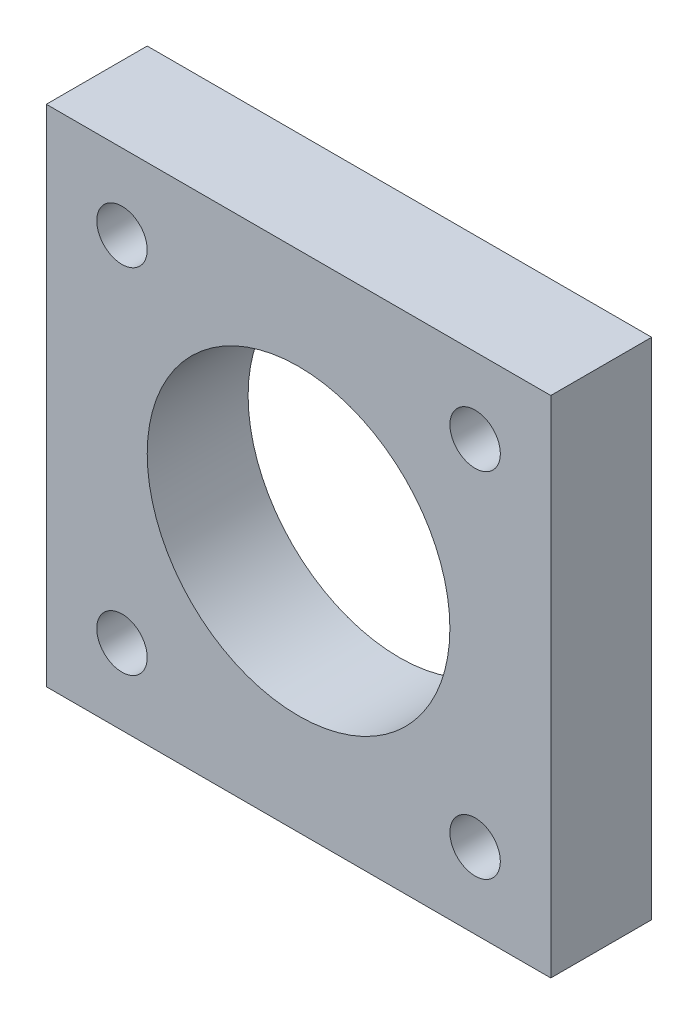
from build123d import *

# Parameters (mm, degrees)
SKETCH1_R           = 15
SKETCH1_R_2         = 10
BOSS_EXTRUDE1_DEPTH = 30
SKETCH2_W           = 50
SKETCH2_H           = 50
BOSS_EXTRUDE2_DEPTH = 10
SKETCH3_R           = 2.5
CUT_EXTRUDE1_DEPTH  = 10
SKETCH4_R           = 15
SKETCH4_R_2         = 10
CUT_EXTRUDE2_DEPTH  = 30
SKETCH5_R           = 15
CUT_EXTRUDE3_DEPTH  = 30


with BuildPart() as part:
    # Sketch1 → Boss-Extrude1 (new body)
    with BuildSketch(Plane.XY):
        Circle(SKETCH1_R)
        Circle(SKETCH1_R_2, mode=Mode.SUBTRACT)
    extrude(amount=BOSS_EXTRUDE1_DEPTH)

    # Sketch2 → Boss-Extrude2 (add)
    with BuildSketch(Plane(origin=(0, 0, 0), x_dir=(-1, 0, 0), z_dir=(0, 0, -1))):
        Rectangle(SKETCH2_W, SKETCH2_H)
    extrude(amount=BOSS_EXTRUDE2_DEPTH)

    # Sketch3 → Cut-Extrude1 (cut)
    with BuildSketch(Plane.XY):
        with Locations((-17.5, 17.5)):
            Circle(SKETCH3_R)
        with Locations((-17.5, -17.5)):
            Circle(SKETCH3_R)
        with Locations((17.5, -17.5)):
            Circle(SKETCH3_R)
        with Locations((17.5, 17.5)):
            Circle(SKETCH3_R)
    extrude(amount=-CUT_EXTRUDE1_DEPTH, mode=Mode.SUBTRACT)

    # Sketch4 → Cut-Extrude2 (cut)
    with BuildSketch(Plane.XY):
        Circle(SKETCH4_R)
        Circle(SKETCH4_R_2, mode=Mode.SUBTRACT)
    extrude(amount=CUT_EXTRUDE2_DEPTH, mode=Mode.SUBTRACT)

    # Sketch5 → Cut-Extrude3 (cut)
    with BuildSketch(Plane.XY):
        Circle(SKETCH5_R)
    extrude(amount=-CUT_EXTRUDE3_DEPTH, mode=Mode.SUBTRACT)


solid = part.part
